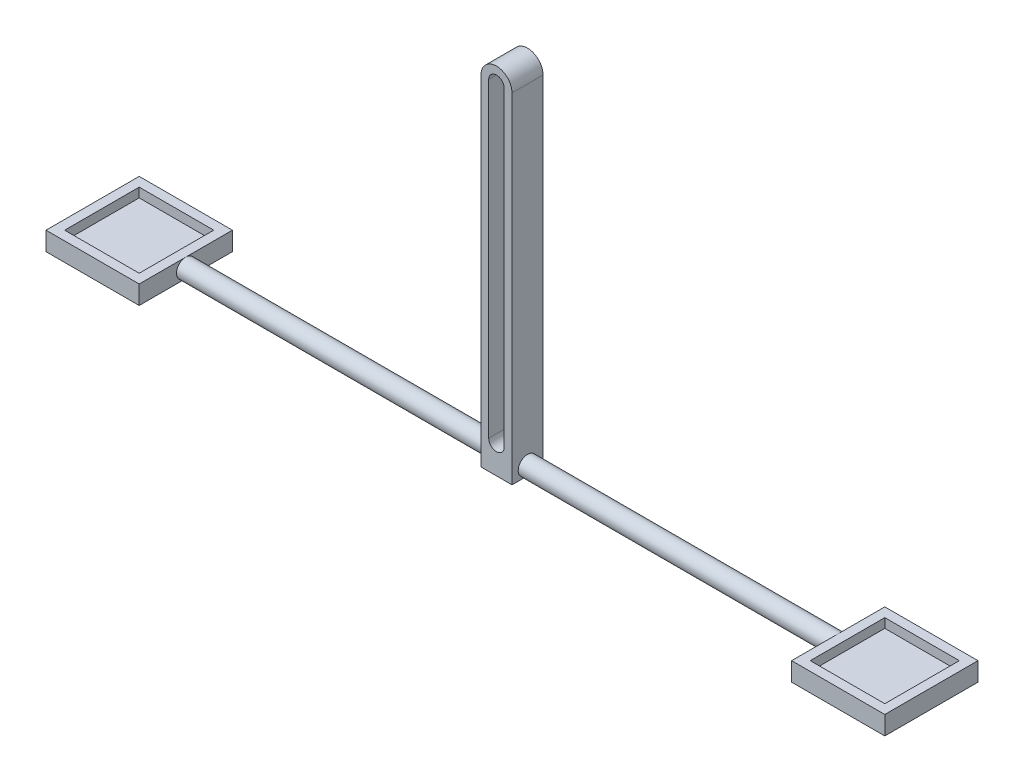
from build123d import *

# Parameters (mm, degrees)
BOSS_EXTRUDE2_DEPTH      = 10
SKETCH3_R                = 3
BOSS_EXTRUDE3_DEPTH      = 100
BOSS_EXTRUDE3_DEPTH_BACK = 110
BOSS_EXTRUDE4_DEPTH      = 3
BOSS_EXTRUDE5_DEPTH      = 3
BOSS_EXTRUDE6_DEPTH      = 3
CUT_EXTRUDE1_REACH       = 22
SKETCH9_W                = 10
SKETCH9_H                = 0.75


with BuildPart() as part:
    # Sketch1 → Boss-Extrude2 (new body)
    with BuildSketch(Plane.XY):
        with BuildLine():
            Line((5, 100), (5, 0))
            Line((5, 0), (5, -10))
            Line((5, -10), (-5, -10))
            Line((-5, -10), (-5, 0))
            Line((-5, 0), (-5, 100))
            ThreePointArc((-5, 100), (0, 105), (5, 100))
        make_face()
        with BuildLine():
            Line((-2.5, 0), (-2.5, 100))
            ThreePointArc((-2.5, 100), (0, 102.5), (2.5, 100))
            Line((2.5, 100), (2.5, 0))
            ThreePointArc((2.5, 0), (0, -2.5), (-2.5, 0))
        make_face(mode=Mode.SUBTRACT)
    extrude(amount=BOSS_EXTRUDE2_DEPTH)

    # Sketch3 → Boss-Extrude3 (add, two sides)
    with BuildSketch(Plane(origin=(5, 0, 0), x_dir=(0, 0, -1), z_dir=(1, 0, 0))) as boss_extrude3_sk:
        with Locations((-5, -6.25)):
            Circle(SKETCH3_R)
    extrude(amount=BOSS_EXTRUDE3_DEPTH)
    extrude(boss_extrude3_sk.sketch, amount=-BOSS_EXTRUDE3_DEPTH_BACK)

    # Sketch6 → Boss-Extrude4 (add)
    with BuildSketch(Plane(origin=(0, -9.25, 0), x_dir=(-1, 0, 0), z_dir=(0, -1, 0))):
        Polygon((-105, -2), (-105, 10), (-135, 10), (-135, -20), (-105, -20), (-105, -8), align=None)
        Polygon((105, -2), (105, 10), (135, 10), (135, -20), (105, -20), (105, -8), align=None)
    extrude(amount=-BOSS_EXTRUDE4_DEPTH)

    # Sketch7 → Boss-Extrude5 (add)
    with BuildSketch(Plane(origin=(0, -6.25, 0), x_dir=(1, 0, 0), z_dir=(0, 1, 0))):
        Polygon((-105, -2), (-105, 10), (-135, 10), (-135, -20), (-105, -20), (-105, -8), align=None)
        Polygon((-108, -2), (-108, 7), (-132, 7), (-132, -17), (-108, -17), (-108, -8), align=None, mode=Mode.SUBTRACT)
    extrude(amount=BOSS_EXTRUDE5_DEPTH)

    # Sketch8 → Boss-Extrude6 (add)
    with BuildSketch(Plane(origin=(0, -6.25, 0), x_dir=(1, 0, 0), z_dir=(0, 1, 0))):
        Polygon((135, -2), (135, 10), (105, 10), (105, -20), (135, -20), (135, -8), align=None)
        Polygon((132, -2), (132, 7), (108, 7), (108, -17), (132, -17), (132, -8), align=None, mode=Mode.SUBTRACT)
    extrude(amount=BOSS_EXTRUDE6_DEPTH)

    # Sketch9 → Cut-Extrude1 (cut, up to next)
    with BuildSketch(Plane.XY.offset(10), mode=Mode.PRIVATE) as cut_extrude1_sk1:
        with Locations((0, -9.625)):
            Rectangle(SKETCH9_W, SKETCH9_H)
    cut_extrude1_tool1 = extrude(cut_extrude1_sk1.sketch, amount=-CUT_EXTRUDE1_REACH, mode=Mode.PRIVATE) & part.part
    add(cut_extrude1_tool1.solids().sort_by_distance((0, -9.625, 10))[0], mode=Mode.SUBTRACT)


solid = part.part
